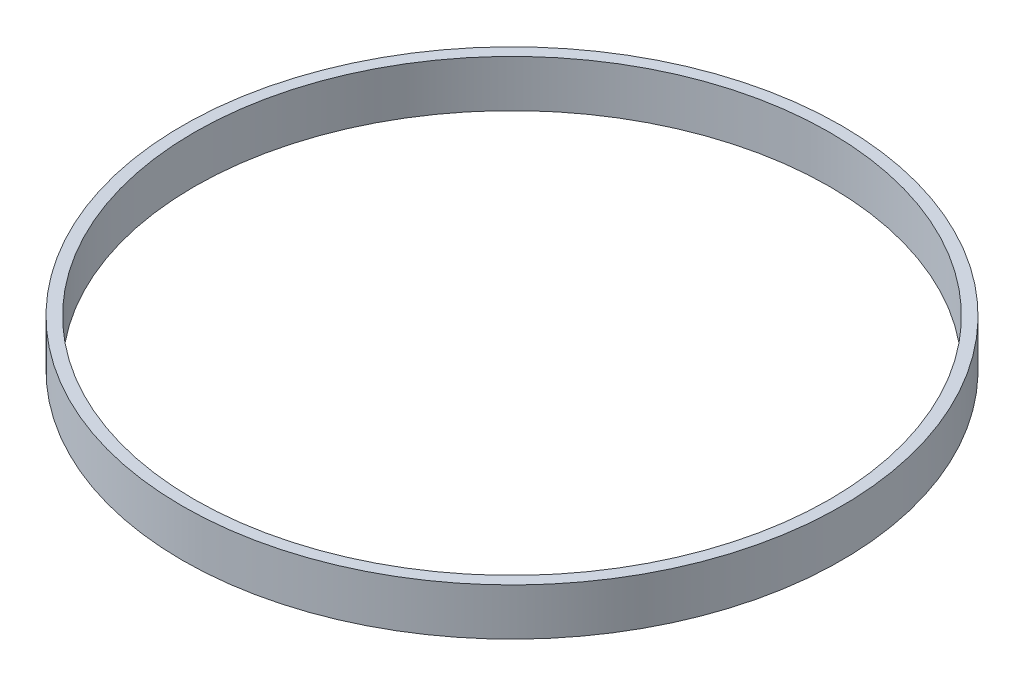
from build123d import *

# Parameters (mm, degrees)
SKETCH1_R           = 89.1286
SKETCH1_R_2         = 85.9536
BOSS_EXTRUDE1_DEPTH = 6.35


with BuildPart() as part:
    # Sketch1 → Boss-Extrude1 (new body, symmetric)
    with BuildSketch(Plane(origin=(0, 0, 0), x_dir=(1, 0, 0), z_dir=(0, 1, 0))):
        Circle(SKETCH1_R)
        Circle(SKETCH1_R_2, mode=Mode.SUBTRACT)
    extrude(amount=BOSS_EXTRUDE1_DEPTH, both=True)


solid = part.part
